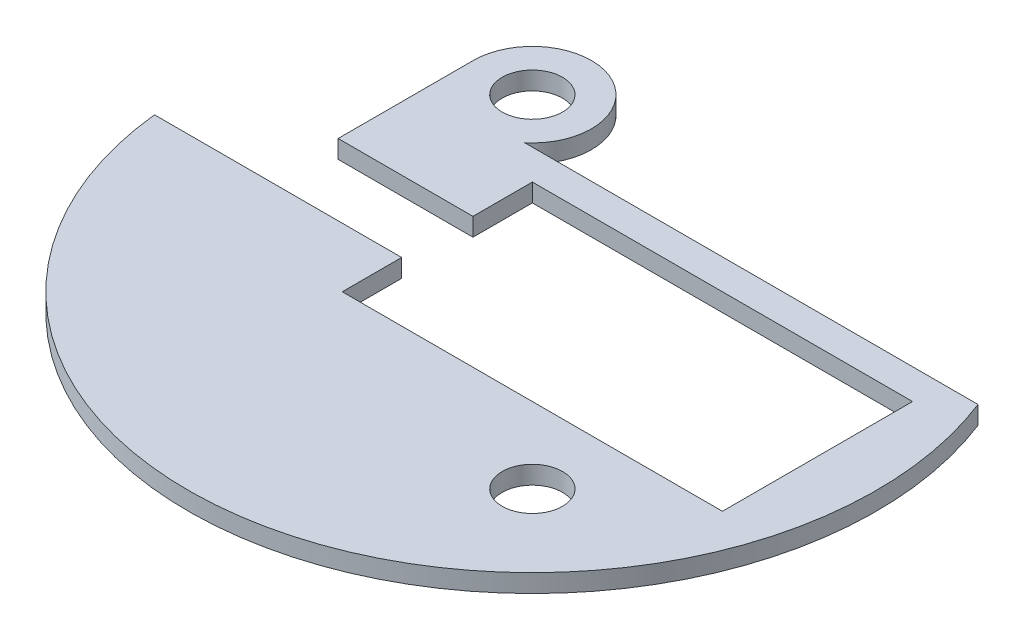
from build123d import *

# Parameters (mm, degrees)
SKETCH2_R           = 3.175
BOSS_EXTRUDE1_DEPTH = 1.905


with BuildPart() as part:
    # Sketch2 → Boss-Extrude1 (new body)
    with BuildSketch(Plane(origin=(0, 0, 0), x_dir=(1, 0, 0), z_dir=(0, 1, 0))):
        with BuildLine():
            Line((-24.183512242, 17.960512242), (-24.183512242, 3.75))
            Line((-24.183512242, 3.75), (-10, 3.75))
            Line((-10, 3.75), (-10, 10))
            Line((-10, 10), (30, 10))
            Line((30, 10), (30, -10))
            Line((30, -10), (11.737512242, -10))
            Line((11.737512242, -10), (10, -10))
            Line((10, -10), (0, -10))
            Line((0, -10), (-10, -10))
            Line((-10, -10), (-10, -3.75))
            Line((-10, -3.75), (-24.183512242, -3.75))
            Line((-24.183512242, -3.75), (-36.000215624, -3.75))
            ThreePointArc((-36.000215624, -3.75), (8.539491503, -35.173215802), (33.7119771, 13.175))
            Line((33.7119771, 13.175), (-13.982497463, 13.175))
            ThreePointArc((-13.982497463, 13.175), (-12.326645232, 15.317545819), (-11.737512242, 17.960512242))
            ThreePointArc((-11.737512242, 17.960512242), (-13.560186743, 22.360837741), (-17.960512242, 24.183512242))
            ThreePointArc((-17.960512242, 24.183512242), (-22.360837741, 22.360837741), (-24.183512242, 17.960512242))
        make_face()
        with Locations((-17.960512242, 17.960512242)):
            Circle(SKETCH2_R, mode=Mode.SUBTRACT)
        with Locations((17.960512242, -17.960512242)):
            Circle(SKETCH2_R, mode=Mode.SUBTRACT)
    extrude(amount=BOSS_EXTRUDE1_DEPTH)


solid = part.part
